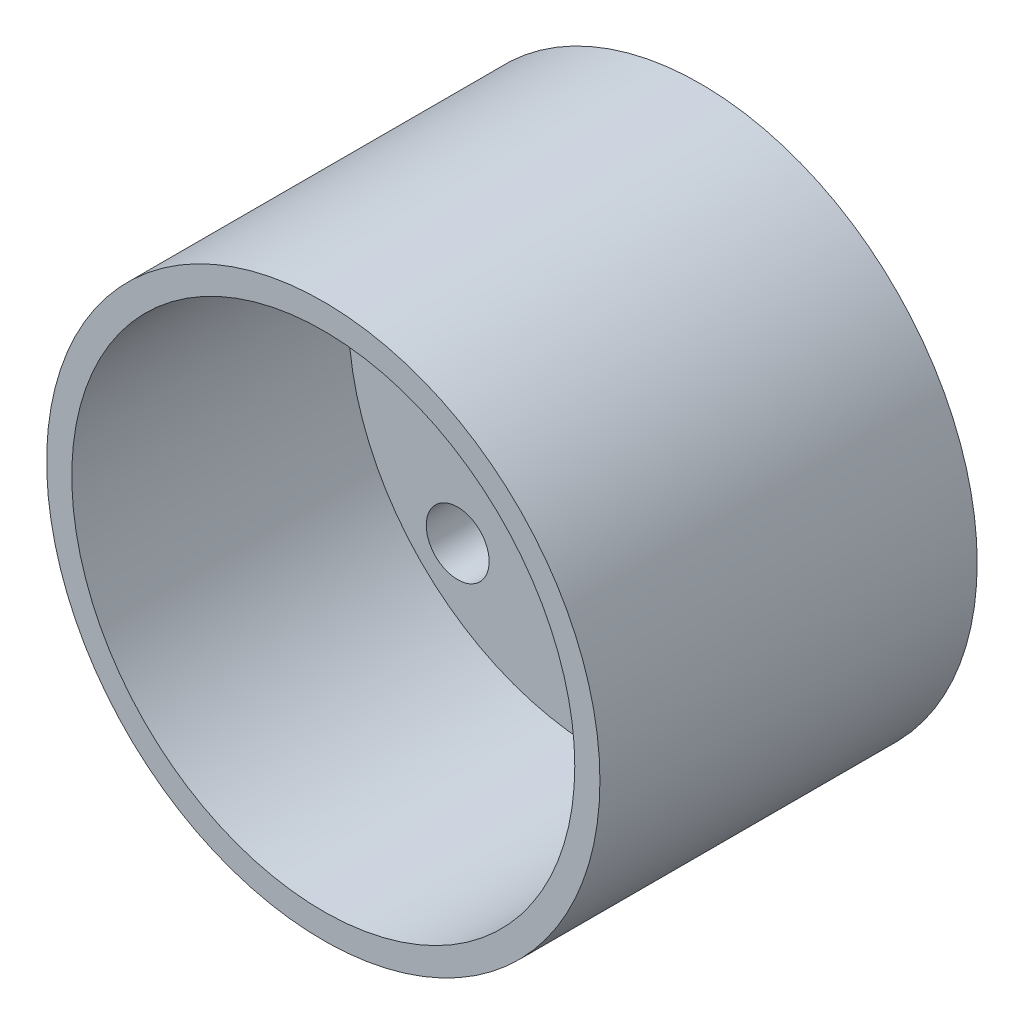
from build123d import *

# Parameters (mm, degrees)
SKETCH1_R           = 11
BOSS_EXTRUDE1_DEPTH = 15
SKETCH3_R           = 10
CUT_EXTRUDE1_DEPTH  = 11
SKETCH4_R           = 4.15
SKETCH4_R_2         = 1.25
CUT_EXTRUDE2_DEPTH  = 11


with BuildPart() as part:
    # Sketch1 → Boss-Extrude1 (new body)
    with BuildSketch(Plane.XY):
        Circle(SKETCH1_R)
    extrude(amount=BOSS_EXTRUDE1_DEPTH)

    # Sketch3 → Cut-Extrude1 (cut)
    with BuildSketch(Plane.XY.offset(15)):
        Circle(SKETCH3_R)
    extrude(amount=-CUT_EXTRUDE1_DEPTH, mode=Mode.SUBTRACT)

    # Sketch4 → Cut-Extrude2 (cut)
    with BuildSketch(Plane(origin=(0, 0, 0), x_dir=(-1, 0, 0), z_dir=(0, 0, -1))):
        Circle(SKETCH4_R)
        with Locations((0, 8)):
            Circle(SKETCH4_R_2)
        with Locations((5.656854249, 5.656854249)):
            Circle(SKETCH4_R_2)
        with Locations((8, 0)):
            Circle(SKETCH4_R_2)
        with Locations((5.656854249, -5.656854249)):
            Circle(SKETCH4_R_2)
        with Locations((0, -8)):
            Circle(SKETCH4_R_2)
        with Locations((-5.656854249, -5.656854249)):
            Circle(SKETCH4_R_2)
        with Locations((-8, 0)):
            Circle(SKETCH4_R_2)
        with Locations((-5.656854249, 5.656854249)):
            Circle(SKETCH4_R_2)
    extrude(amount=-CUT_EXTRUDE2_DEPTH, mode=Mode.SUBTRACT)


solid = part.part
